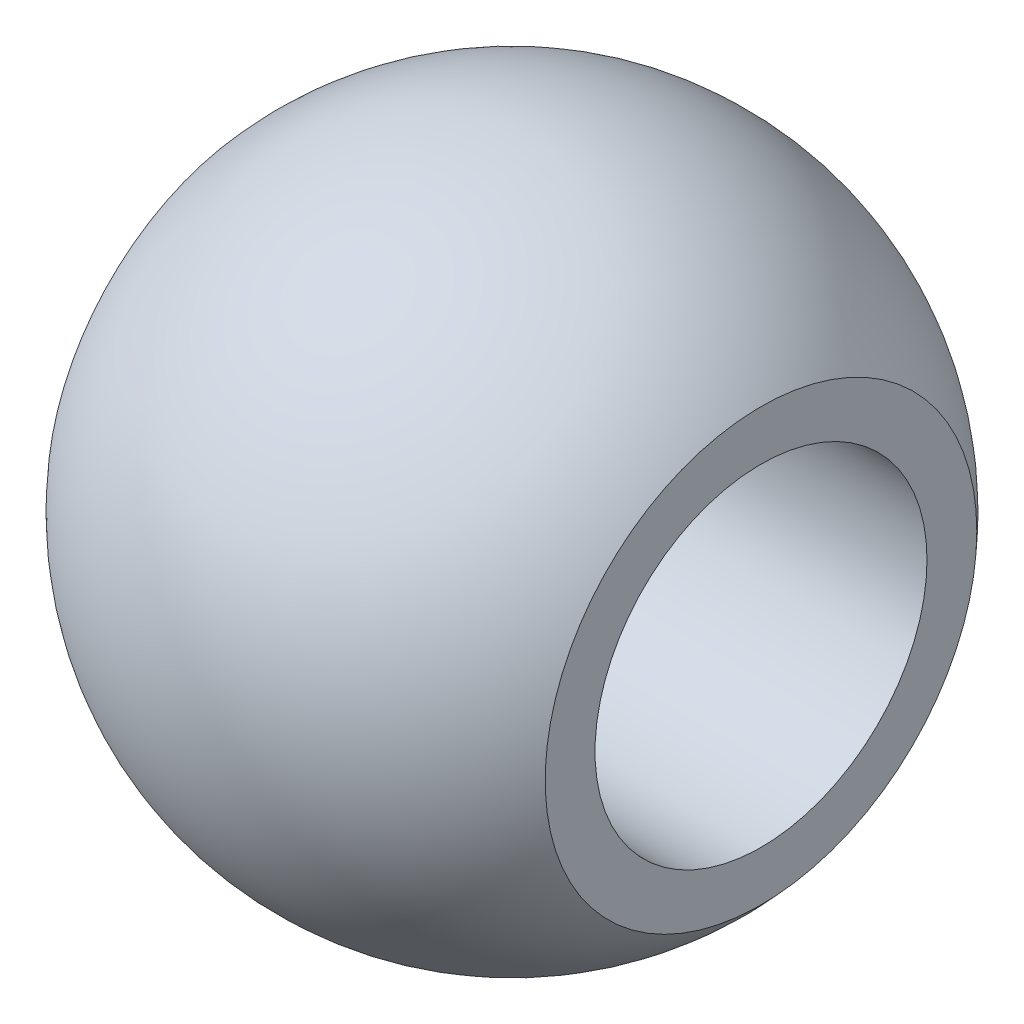
from build123d import *


with BuildPart() as part:
    # Sketch1 → Revolve1 (revolve)
    with BuildSketch(Plane(origin=(0, 0, 0), x_dir=(1, 0, 0), z_dir=(0, 1, 0))):
        with BuildLine():
            Line((6, 4), (-6, 4))
            Line((-6, 4), (-6, 5.200346142))
            ThreePointArc((-6, 5.200346142), (0, 7.94), (6, 5.200346142))
            Line((6, 5.200346142), (6, 4))
        make_face()
    revolve(axis=Axis((6, 0, 0), (-1, 0, 0)))


solid = part.part
